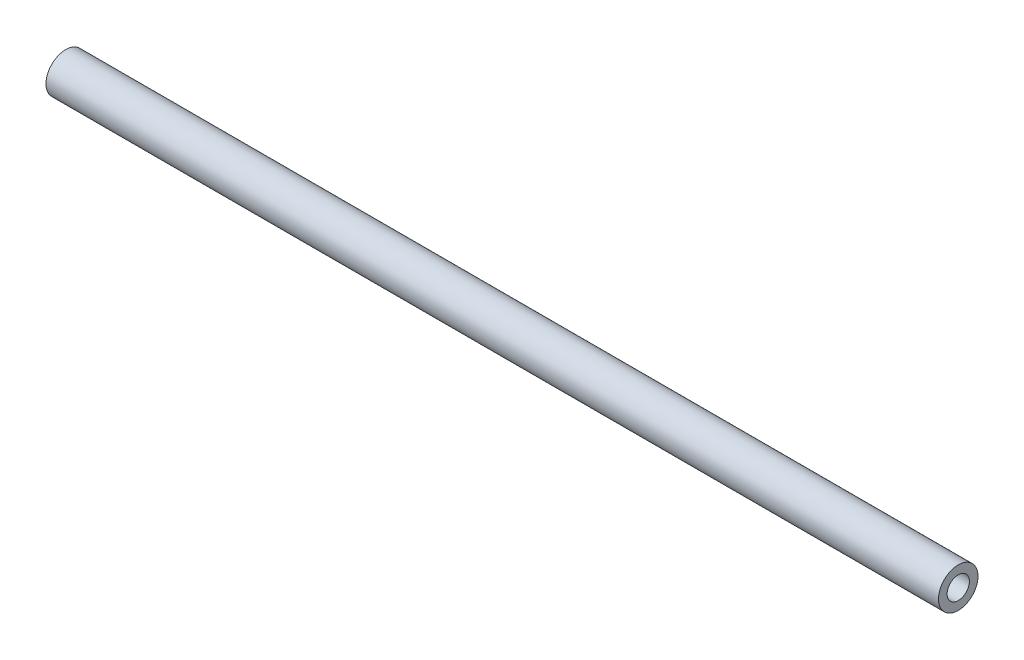
from build123d import *

# Parameters (mm, degrees)
BOSS_EXTRUDE1_DEPTH      = 35
BOSS_EXTRUDE1_DEPTH_BACK = 35
SKETCH1_R                = 1.55


with BuildPart() as part:
    # Sketch1 → Boss-Extrude1 (new, two sides: drawn at the far end of the back side and taken through both)
    with BuildSketch(Plane(origin=(0, 0, 0), x_dir=(0, 0, -1), z_dir=(1, 0, 0)).offset(-BOSS_EXTRUDE1_DEPTH_BACK)):
        Circle(SKETCH1_R)
    extrude(amount=BOSS_EXTRUDE1_DEPTH + BOSS_EXTRUDE1_DEPTH_BACK)

    # Sketch3 → M2x0.25 Tapped Hole1 (revolve, cut)
    with BuildSketch(Plane(origin=(35, 0, 0), x_dir=(0, 0, -1), z_dir=(0, 1, 0))):
        Polygon((0, 0), (0, 10.525753042), (0.875, 10), (0.875, 0), align=None)
    m2x0_25_tapped_hole1 = revolve(axis=Axis((41.35, 0, 0), (-1, 0, 0)), mode=Mode.SUBTRACT)

    # Mirror1: M2x0.25 Tapped Hole1 across plane
    add(m2x0_25_tapped_hole1.mirror(Plane(origin=(0, 0, 0), x_dir=(0, 0, 1), z_dir=(1, 0, 0))), mode=Mode.SUBTRACT)


solid = part.part
